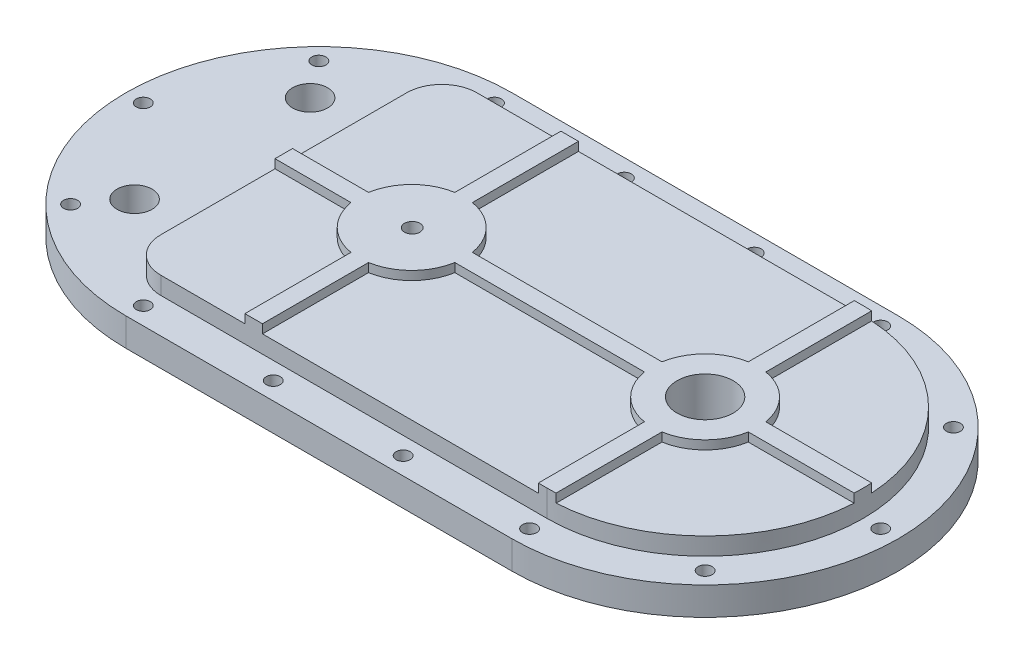
from build123d import *

# Parameters (mm, degrees)
BOSS_EXTRUDE1_DEPTH     = 16
F_8_0MM_DOWEL_HOLE1_D   = 8
CIRPATTERN2_COUNT       = 5
CIRPATTERN2_ANGLE       = 180
MIRROR2_COPY_1_D        = 8
MIRROR2_COPY_2_D        = 8
MIRROR2_COPY_3_D        = 8
MIRROR2_COPY_4_D        = 8
LPATTERN1_COUNT         = 3
LPATTERN1_PITCH         = 74
MIRROR3_COPY_1_D        = 8
MIRROR3_COPY_2_D        = 8
MIRROR3_COPY_3_D        = 8
SKETCH13_R              = 4
SKETCH13_R_2            = 10
BOSS_EXTRUDE2_DEPTH     = 16
BOSS_EXTRUDE3_DEPTH     = 26
SKETCH16_W              = 10
SKETCH16_H              = 10
BOSS_EXTRUDE5_DEPTH     = 5
M10X1_25_TAPPED_HOLE1_D = 8.8
SKETCH19_R              = 16
CUT_EXTRUDE1_DEPTH      = 32


with BuildPart() as part:
    # Sketch1 → Boss-Extrude1 (new body)
    with BuildSketch(Plane(origin=(0, 0, 0), x_dir=(1, 0, 0), z_dir=(0, 1, 0))):
        with BuildLine():
            Line((-110, 110), (110, 110))
            ThreePointArc((110, 110), (220, 0), (110, -110))
            Line((110, -110), (-110, -110))
            ThreePointArc((-110, -110), (-220, 0), (-110, 110))
        make_face()
        with BuildLine():
            Line((-110, 90), (110, 90))
            ThreePointArc((110, 90), (200, 0), (110, -90))
            Line((110, -90), (-110, -90))
            ThreePointArc((-110, -90), (-200, 0), (-110, 90))
        make_face(mode=Mode.SUBTRACT)
    extrude(amount=BOSS_EXTRUDE1_DEPTH)

    # Ø8.0mm Dowel Hole1 (through all)
    with Locations(Plane(origin=(-110, 16, -100), x_dir=(0, 0, 1), z_dir=(0, 1, 0))):
        with Locations((0, 0)):
            f_8_0mm_dowel_hole1 = Hole(F_8_0MM_DOWEL_HOLE1_D / 2)

    # CirPattern2: Ø8.0mm Dowel Hole1 ×5 about axis
    cirpattern2_axis = Axis((-110, 0, 0), (0, 1, 0))
    for i in range(1, CIRPATTERN2_COUNT):
        add(f_8_0mm_dowel_hole1.rotate(cirpattern2_axis, i * CIRPATTERN2_ANGLE / (CIRPATTERN2_COUNT - 1)), mode=Mode.SUBTRACT)

    # Mirror2: Ø8.0mm Dowel Hole1 across plane
    add(f_8_0mm_dowel_hole1.mirror(Plane(origin=(0, 0, 0), x_dir=(0, 0, 1), z_dir=(1, 0, 0))), mode=Mode.SUBTRACT)

    # Mirror2 copy 1 (through all)
    with Locations(Plane(origin=(180.710678119, 16, -70.710678119), x_dir=(-0.707106781, 0, 0.707106781), z_dir=(0, 1, 0))):
        with Locations((0, 0)):
            Hole(MIRROR2_COPY_1_D / 2)

    # Mirror2 copy 2 (through all)
    with Locations(Plane(origin=(210, 16, 0), x_dir=(-1, 0, 0), z_dir=(0, 1, 0))):
        with Locations((0, 0)):
            Hole(MIRROR2_COPY_2_D / 2)

    # Mirror2 copy 3 (through all)
    with Locations(Plane(origin=(180.710678119, 16, 70.710678119), x_dir=(-0.707106781, 0, -0.707106781), z_dir=(0, 1, 0))):
        with Locations((0, 0)):
            Hole(MIRROR2_COPY_3_D / 2)

    # Mirror2 copy 4 (through all)
    with Locations(Plane(origin=(110, 16, 100), x_dir=(0, 0, -1), z_dir=(0, 1, 0))):
        with Locations((0, 0)):
            Hole(MIRROR2_COPY_4_D / 2)

    # LPattern1: Ø8.0mm Dowel Hole1 ×3
    with Locations(*[(i * LPATTERN1_PITCH, 0, 0) for i in range(1, LPATTERN1_COUNT)]):
        add(f_8_0mm_dowel_hole1, mode=Mode.SUBTRACT)

    # Mirror3 copy 1 (through all)
    with Locations(Plane(origin=(-36, 16, 100), x_dir=(0, 0, -1), z_dir=(0, 1, 0))):
        with Locations((0, 0)):
            Hole(MIRROR3_COPY_1_D / 2)

    # Mirror3 copy 2 (through all)
    with Locations(Plane(origin=(38, 16, 100), x_dir=(0, 0, -1), z_dir=(0, 1, 0))):
        with Locations((0, 0)):
            Hole(MIRROR3_COPY_2_D / 2)

    # Mirror3 copy 3 (through all)
    with Locations(Plane(origin=(-110, 16, 100), x_dir=(0, 0, -1), z_dir=(0, 1, 0))):
        with Locations((0, 0)):
            Hole(MIRROR3_COPY_3_D / 2)

    # Sketch13 → Boss-Extrude2 (add)
    with BuildSketch(Plane(origin=(0, 0, 0), x_dir=(1, 0, 0), z_dir=(0, 1, 0))):
        with BuildLine():
            Line((-110, -110), (110, -110))
            ThreePointArc((110, -110), (220, 0), (110, 110))
            Line((110, 110), (-110, 110))
            ThreePointArc((-110, 110), (-220, 0), (-110, -110))
        make_face()
        with Locations((38, -100)):
            Circle(SKETCH13_R, mode=Mode.SUBTRACT)
        with Locations((-110, 100)):
            Circle(SKETCH13_R, mode=Mode.SUBTRACT)
        with Locations((-180.710678119, 70.710678119)):
            Circle(SKETCH13_R, mode=Mode.SUBTRACT)
        with Locations((-210, 0)):
            Circle(SKETCH13_R, mode=Mode.SUBTRACT)
        with Locations((-180.710678119, -70.710678119)):
            Circle(SKETCH13_R, mode=Mode.SUBTRACT)
        with Locations((-110, -100)):
            Circle(SKETCH13_R, mode=Mode.SUBTRACT)
        with Locations((110, 100)):
            Circle(SKETCH13_R, mode=Mode.SUBTRACT)
        with Locations((180.710678119, 70.710678119)):
            Circle(SKETCH13_R, mode=Mode.SUBTRACT)
        with Locations((210, 0)):
            Circle(SKETCH13_R, mode=Mode.SUBTRACT)
        with Locations((180.710678119, -70.710678119)):
            Circle(SKETCH13_R, mode=Mode.SUBTRACT)
        with Locations((110, -100)):
            Circle(SKETCH13_R, mode=Mode.SUBTRACT)
        with Locations((-36, 100)):
            Circle(SKETCH13_R, mode=Mode.SUBTRACT)
        with Locations((38, 100)):
            Circle(SKETCH13_R, mode=Mode.SUBTRACT)
        with Locations((-36, -100)):
            Circle(SKETCH13_R, mode=Mode.SUBTRACT)
        with Locations((-165, -50)):
            Circle(SKETCH13_R_2, mode=Mode.SUBTRACT)
        with Locations((-165, 50)):
            Circle(SKETCH13_R_2, mode=Mode.SUBTRACT)
    extrude(amount=BOSS_EXTRUDE2_DEPTH)

    # Sketch15 → Boss-Extrude3 (add)
    with BuildSketch(Plane(origin=(0, 0, 0), x_dir=(1, 0, 0), z_dir=(0, 1, 0))):
        with BuildLine():
            ThreePointArc((-130, 70), (-124.142135624, 84.142135624), (-110, 90))
            Line((-110, 90), (110, 90))
            Line((110, 90), (110, -90))
            Line((110, -90), (-110, -90))
            ThreePointArc((-110, -90), (-124.142135624, -84.142135624), (-130, -70))
            Line((-130, -70), (-130, 70))
        make_face()
        with BuildLine():
            ThreePointArc((110, 90), (200, 0), (110, -90))
            Line((110, -90), (110, 90))
        make_face()
    extrude(amount=BOSS_EXTRUDE3_DEPTH)

    # Sketch16 → Boss-Extrude5 (add)
    with BuildSketch(Plane(origin=(0, 26, 0), x_dir=(1, 0, 0), z_dir=(0, 1, 0))):
        with BuildLine():
            Line((-62.14, 29.580398915), (-62.14, 5))
            Line((-62.14, 5), (-52.14, 5))
            Line((-52.14, 5), (-52.14, 29.580398915))
            ThreePointArc((-52.14, 29.580398915), (-57.14, 30), (-62.14, 29.580398915))
        make_face()
        with BuildLine():
            Line((-52.14, 90), (-62.14, 90))
            Line((-62.14, 90), (-62.14, 29.580398915))
            ThreePointArc((-62.14, 29.580398915), (-57.14, 30), (-52.14, 29.580398915))
            Line((-52.14, 29.580398915), (-52.14, 90))
        make_face()
        with BuildLine():
            Line((-52.14, 29.580398915), (-52.14, 5))
            Line((-52.14, 5), (-27.559601085, 5))
            ThreePointArc((-27.559601085, 5), (-35.926796564, 21.213203436), (-52.14, 29.580398915))
        make_face()
        with BuildLine():
            Line((-27.559601085, 5), (-52.14, 5))
            Line((-52.14, 5), (-52.14, -5))
            Line((-52.14, -5), (-27.559601085, -5))
            ThreePointArc((-27.559601085, -5), (-27.245084316, -2.508787808), (-27.14, 0))
            ThreePointArc((-27.14, 0), (-27.245084316, 2.508787808), (-27.559601085, 5))
        make_face()
        with Locations((-57.14, 0)):
            Rectangle(SKETCH16_W, SKETCH16_H)
        with BuildLine():
            Line((-52.14, -5), (-62.14, -5))
            Line((-62.14, -5), (-62.14, -29.580398915))
            ThreePointArc((-62.14, -29.580398915), (-57.14, -30), (-52.14, -29.580398915))
            Line((-52.14, -29.580398915), (-52.14, -5))
        make_face()
        with BuildLine():
            Line((-62.14, 5), (-86.720398915, 5))
            ThreePointArc((-86.720398915, 5), (-87.14, 0), (-86.720398915, -5))
            Line((-86.720398915, -5), (-62.14, -5))
            Line((-62.14, -5), (-62.14, 5))
        make_face()
        with BuildLine():
            ThreePointArc((-62.14, 29.580398915), (-78.353203436, 21.213203436), (-86.720398915, 5))
            Line((-86.720398915, 5), (-62.14, 5))
            Line((-62.14, 5), (-62.14, 29.580398915))
        make_face()
        with BuildLine():
            Line((-62.14, -5), (-86.720398915, -5))
            ThreePointArc((-86.720398915, -5), (-78.353203436, -21.213203436), (-62.14, -29.580398915))
            Line((-62.14, -29.580398915), (-62.14, -5))
        make_face()
        with BuildLine():
            Line((-27.559601085, -5), (-52.14, -5))
            Line((-52.14, -5), (-52.14, -29.580398915))
            ThreePointArc((-52.14, -29.580398915), (-35.926796564, -21.213203436), (-27.559601085, -5))
        make_face()
        with BuildLine():
            Line((26.43, 5), (-27.559601085, 5))
            ThreePointArc((-27.559601085, 5), (-27.245084316, 2.508787808), (-27.14, 0))
            ThreePointArc((-27.14, 0), (-27.245084316, -2.508787808), (-27.559601085, -5))
            Line((-27.559601085, -5), (26.43, -5))
            Line((26.43, -5), (80.419601085, -5))
            ThreePointArc((80.419601085, -5), (80, 0), (80.419601085, 5))
            Line((80.419601085, 5), (26.43, 5))
        make_face()
        with BuildLine():
            Line((-86.720398915, 5), (-130, 5))
            Line((-130, 5), (-130, -5))
            Line((-130, -5), (-86.720398915, -5))
            ThreePointArc((-86.720398915, -5), (-87.14, 0), (-86.720398915, 5))
        make_face()
        with BuildLine():
            ThreePointArc((-52.14, -29.580398915), (-57.14, -30), (-62.14, -29.580398915))
            Line((-62.14, -29.580398915), (-62.14, -90))
            Line((-62.14, -90), (-52.14, -90))
            Line((-52.14, -90), (-52.14, -29.580398915))
        make_face()
        with BuildLine():
            ThreePointArc((139.580398915, 5), (131.213203436, 21.213203436), (115, 29.580398915))
            Line((115, 29.580398915), (115, 5))
            Line((115, 5), (139.580398915, 5))
        make_face()
        with BuildLine():
            ThreePointArc((115, 29.580398915), (110, 30), (105, 29.580398915))
            Line((105, 29.580398915), (105, 5))
            Line((105, 5), (115, 5))
            Line((115, 5), (115, 29.580398915))
        make_face()
        with BuildLine():
            Line((105, 5), (105, 29.580398915))
            ThreePointArc((105, 29.580398915), (88.786796564, 21.213203436), (80.419601085, 5))
            Line((80.419601085, 5), (105, 5))
        make_face()
        with BuildLine():
            Line((105, -5), (105, 5))
            Line((105, 5), (80.419601085, 5))
            ThreePointArc((80.419601085, 5), (80, 0), (80.419601085, -5))
            Line((80.419601085, -5), (105, -5))
        make_face()
        with Locations((110, 0)):
            Rectangle(SKETCH16_W, SKETCH16_H)
        with BuildLine():
            Line((139.580398915, 5), (115, 5))
            Line((115, 5), (115, -5))
            Line((115, -5), (139.580398915, -5))
            ThreePointArc((139.580398915, -5), (139.894915684, -2.508787808), (140, 0))
            ThreePointArc((140, 0), (139.894915684, 2.508787808), (139.580398915, 5))
        make_face()
        with BuildLine():
            Line((139.580398915, -5), (115, -5))
            Line((115, -5), (115, -29.580398915))
            ThreePointArc((115, -29.580398915), (131.213203436, -21.213203436), (139.580398915, -5))
        make_face()
        with BuildLine():
            Line((115, -5), (105, -5))
            Line((105, -5), (105, -29.580398915))
            ThreePointArc((105, -29.580398915), (110, -30), (115, -29.580398915))
            Line((115, -29.580398915), (115, -5))
        make_face()
        with BuildLine():
            Line((105, -29.580398915), (105, -5))
            Line((105, -5), (80.419601085, -5))
            ThreePointArc((80.419601085, -5), (88.786796564, -21.213203436), (105, -29.580398915))
        make_face()
        with BuildLine():
            ThreePointArc((199.861003778, -5), (200, 0), (199.861003778, 5))
            Line((199.861003778, 5), (139.580398915, 5))
            ThreePointArc((139.580398915, 5), (139.894915684, 2.508787808), (140, 0))
            ThreePointArc((140, 0), (139.894915684, -2.508787808), (139.580398915, -5))
            Line((139.580398915, -5), (199.861003778, -5))
        make_face()
        with BuildLine():
            Line((110, 90), (105, 90))
            Line((105, 90), (105, 29.580398915))
            ThreePointArc((105, 29.580398915), (110, 30), (115, 29.580398915))
            Line((115, 29.580398915), (115, 89.861003778))
            ThreePointArc((115, 89.861003778), (112.500965811, 89.965244234), (110, 90))
        make_face()
        with BuildLine():
            Line((105, -29.580398915), (105, -90))
            Line((105, -90), (110, -90))
            ThreePointArc((110, -90), (112.500965811, -89.965244234), (115, -89.861003778))
            Line((115, -89.861003778), (115, -29.580398915))
            ThreePointArc((115, -29.580398915), (110, -30), (105, -29.580398915))
        make_face()
    extrude(amount=BOSS_EXTRUDE5_DEPTH)

    # M10x1.25 Tapped Hole1 (through all)
    with Locations(Plane(origin=(-56.866813058, 31, 0), x_dir=(0, 0, 1), z_dir=(0, 1, 0))):
        with Locations((0, 0)):
            Hole(M10X1_25_TAPPED_HOLE1_D / 2)

    # Sketch19 → Cut-Extrude1 (cut, through all)
    with BuildSketch(Plane(origin=(0, 31, 0), x_dir=(1, 0, 0), z_dir=(0, 1, 0))):
        with Locations((110, 0)):
            Circle(SKETCH19_R)
    extrude(amount=-CUT_EXTRUDE1_DEPTH, mode=Mode.SUBTRACT)


solid = part.part
